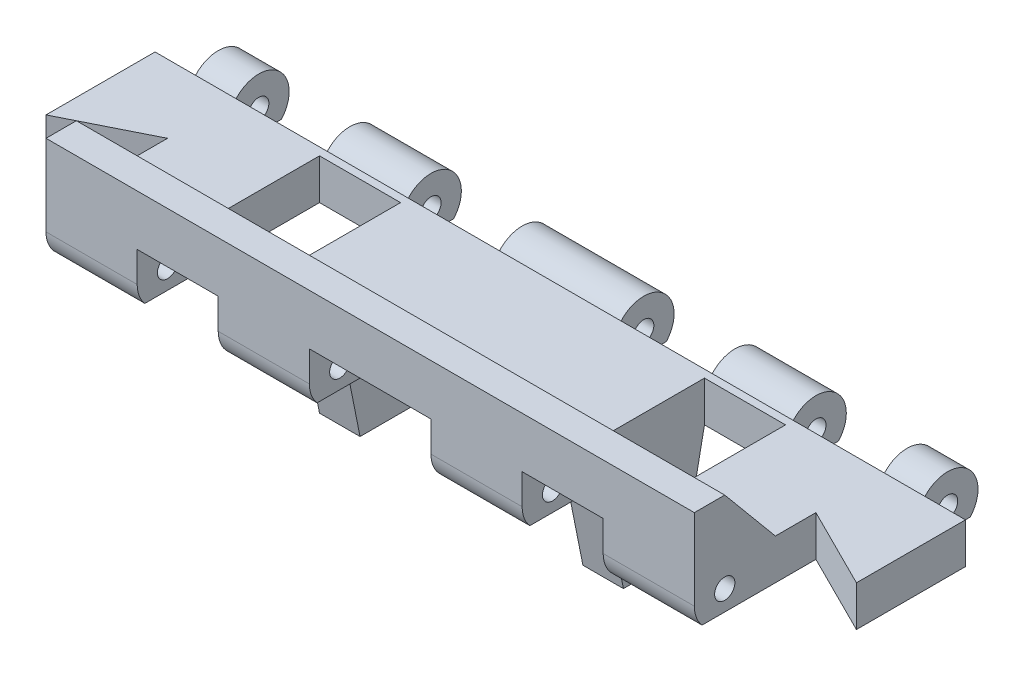
from build123d import *

# Parameters (mm, degrees)
SALIENTE_EXTRUIR1_DEPTH      = 1
SALIENTE_EXTRUIR1_DEPTH_BACK = 1
CROQUIS2_R                   = 0.5
SALIENTE_EXTRUIR2_DEPTH      = 40
CORTAR_EXTRUIR1_DEPTH        = 40
CROQUIS6_R                   = 0.5
CORTAR_EXTRUIR2_DEPTH        = 2
CORTAR_EXTRUIR3_START        = -2
CROQUIS7_R                   = 0.5
CORTAR_EXTRUIR3_DEPTH        = 2
CROQUIS9_R                   = 0.5
SALIENTE_EXTRUIR3_DEPTH      = 32
CORTAR_EXTRUIR4_DEPTH        = 36
CROQUIS11_W                  = 4.5
CROQUIS11_H                  = 2.618033989
CORTAR_EXTRUIR5_DEPTH        = 36
CROQUIS14_W                  = 4
CROQUIS14_H                  = 2.5
CROQUIS14_W_2                = 6
CORTAR_EXTRUIR6_DEPTH        = 3
SALIENTE_EXTRUIR4_DEPTH      = 2
SALIENTE_EXTRUIR5_DEPTH      = 2


with BuildPart() as part:
    # Croquis1 → Saliente-Extruir1 (new, two sides: drawn at the far end of the back side and taken through both)
    with BuildSketch(Plane(origin=(0, 0, 0), x_dir=(1, 0, 0), z_dir=(0, 1, 0)).offset(-SALIENTE_EXTRUIR1_DEPTH_BACK)):
        Polygon((-20, 0), (-20, -5), (-16, -3), (-16, -6), (16, -6), (16, -3), (20, -5), (20, 0), (11.5, 0), (11.5, -5), (7.5, -5), (7.5, 0), (-7.5, 0), (-7.5, -5), (-11.5, -5), (-11.5, 0), align=None)
    extrude(amount=SALIENTE_EXTRUIR1_DEPTH + SALIENTE_EXTRUIR1_DEPTH_BACK)

    # Croquis2 → Saliente-Extruir2 (add)
    with BuildSketch(Plane(origin=(20, 0, 0), x_dir=(0, 0, -1), z_dir=(1, 0, 0))):
        with BuildLine():
            Line((0, -1), (0.381966011, -1))
            ThreePointArc((0.381966011, -1), (3, 0), (0.381966011, 1))
            Line((0.381966011, 1), (0, 1))
            Line((0, 1), (0, 0))
            Line((0, 0), (0, -1))
        make_face()
        with Locations((1.5, 0)):
            Circle(CROQUIS2_R, mode=Mode.SUBTRACT)
    extrude(amount=-SALIENTE_EXTRUIR2_DEPTH)

    # Croquis5 → Cortar-Extruir1 (cut)
    with BuildSketch(Plane(origin=(20, 0, 0), x_dir=(0, 0, -1), z_dir=(1, 0, 0))):
        with BuildLine():
            Line((2.618033989, -1), (0.381966011, -1))
            ThreePointArc((0.381966011, -1), (1.5, -1.5), (2.618033989, -1))
        make_face()
    extrude(amount=-CORTAR_EXTRUIR1_DEPTH, mode=Mode.SUBTRACT)

    # Croquis6 → Cortar-Extruir2 (cut)
    with BuildSketch(Plane(origin=(20, 0, 0), x_dir=(0, 0, -1), z_dir=(1, 0, 0))):
        with BuildLine():
            ThreePointArc((2.618033989, -1), (2.5, 1.118033989), (0.381966011, 1))
            Line((0.381966011, 1), (0.381966011, -1))
            Line((0.381966011, -1), (2.618033989, -1))
        make_face()
        with Locations((1.5, 0)):
            Circle(CROQUIS6_R, mode=Mode.SUBTRACT)
    extrude(amount=-CORTAR_EXTRUIR2_DEPTH, mode=Mode.SUBTRACT)

    # Croquis7 → Cortar-Extruir3 (cut)
    with BuildSketch(Plane.ZY.offset(20).offset(CORTAR_EXTRUIR3_START)):
        with BuildLine():
            Line((-0.381966011, -1), (-0.381966011, 1))
            ThreePointArc((-0.381966011, 1), (-2.5, 1.118033989), (-2.618033989, -1))
            Line((-2.618033989, -1), (-0.381966011, -1))
        make_face()
        with Locations((-1.5, 0)):
            Circle(CROQUIS7_R, mode=Mode.SUBTRACT)
    extrude(amount=CORTAR_EXTRUIR3_DEPTH, mode=Mode.SUBTRACT)

    # Croquis9 → Saliente-Extruir3 (add)
    with BuildSketch(Plane.ZY.offset(16)):
        with BuildLine():
            Line((6, -1), (6.381966011, -1))
            ThreePointArc((6.381966011, -1), (8.035233135, -1.401258538), (9, 0))
            Line((9, 0), (9, 4))
            Line((9, 4), (7.5, 4))
            Line((7.5, 4), (5, 1))
            Line((5, 1), (6, 1))
            Line((6, 1), (6, 0))
            Line((6, 0), (6, -1))
        make_face()
        with Locations((7.5, 0)):
            Circle(CROQUIS9_R, mode=Mode.SUBTRACT)
    extrude(amount=-SALIENTE_EXTRUIR3_DEPTH)

    # Croquis10 → Cortar-Extruir4 (cut)
    with BuildSketch(Plane.ZY.offset(16)):
        with BuildLine():
            Line((8.618033989, -1), (6.381966011, -1))
            ThreePointArc((6.381966011, -1), (7.5, -1.5), (8.618033989, -1))
        make_face()
    extrude(amount=-CORTAR_EXTRUIR4_DEPTH, mode=Mode.SUBTRACT)

    # Croquis11 → Cortar-Extruir5 (cut)
    with BuildSketch(Plane.XZ.offset(1)):
        with Locations((-13.75, -1.690983006)):
            Rectangle(CROQUIS11_W, CROQUIS11_H)
        with Locations((5.25, -1.690983006)):
            Rectangle(CROQUIS11_W, CROQUIS11_H)
        with Locations((-5.25, -1.690983006)):
            Rectangle(CROQUIS11_W, CROQUIS11_H)
        with Locations((13.75, -1.690983006)):
            Rectangle(CROQUIS11_W, CROQUIS11_H)
    extrude(amount=-CORTAR_EXTRUIR5_DEPTH, mode=Mode.SUBTRACT)

    # Croquis14 → Cortar-Extruir6 (cut)
    with BuildSketch(Plane.XY.offset(9)):
        with Locations((9.5, 0.25)):
            Rectangle(CROQUIS14_W, CROQUIS14_H)
        with Locations((0, 0.25)):
            Rectangle(CROQUIS14_W_2, CROQUIS14_H)
        with Locations((-9.5, 0.25)):
            Rectangle(CROQUIS14_W, CROQUIS14_H)
    extrude(amount=-CORTAR_EXTRUIR6_DEPTH, mode=Mode.SUBTRACT)

    # Croquis15 → Saliente-Extruir4 (add)
    with BuildSketch(Plane.ZY.offset(7.5)):
        Polygon((5, -1), (0, -1), (1, -6), (4, -6), align=None)
    extrude(amount=-SALIENTE_EXTRUIR4_DEPTH)

    # Croquis16 → Saliente-Extruir5 (add)
    with BuildSketch(Plane(origin=(7.5, 0, 0), x_dir=(0, 0, -1), z_dir=(1, 0, 0))):
        Polygon((0, -1), (-5, -1), (-4, -6), (-1, -6), align=None)
    extrude(amount=-SALIENTE_EXTRUIR5_DEPTH)


solid = part.part
